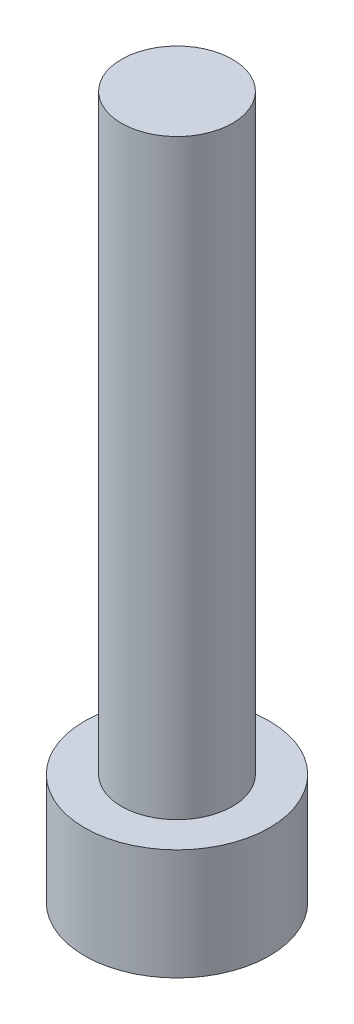
from build123d import *

# Parameters (mm, degrees)
SKETCH_1_R          = 2.5
EXTRUDE_1_DEPTH     = 3
SKETCH_2_R          = 1.5
EXTRUDE_2_DEPTH     = 16
CUT_EXTRUDE_1_DEPTH = 1.65


with BuildPart() as part:
    # 草图1 → 凸台-拉伸1 (new body)
    with BuildSketch(Plane(origin=(0, 0, 0), x_dir=(1, 0, 0), z_dir=(0, 1, 0))):
        Circle(SKETCH_1_R)
    extrude(amount=EXTRUDE_1_DEPTH)

    # 草图2 → 凸台-拉伸2 (add)
    with BuildSketch(Plane(origin=(0, 3, 0), x_dir=(1, 0, 0), z_dir=(0, 1, 0))):
        Circle(SKETCH_2_R)
    extrude(amount=EXTRUDE_2_DEPTH)

    # 草图3 → 切除-拉伸1 (cut)
    with BuildSketch(Plane.XZ):
        Polygon((1.425, 0), (0.7125, 1.2340862), (-0.7125, 1.2340862), (-1.425, 0), (-0.7125, -1.2340862), (0.7125, -1.2340862), align=None)
    extrude(amount=-CUT_EXTRUDE_1_DEPTH, mode=Mode.SUBTRACT)


solid = part.part
